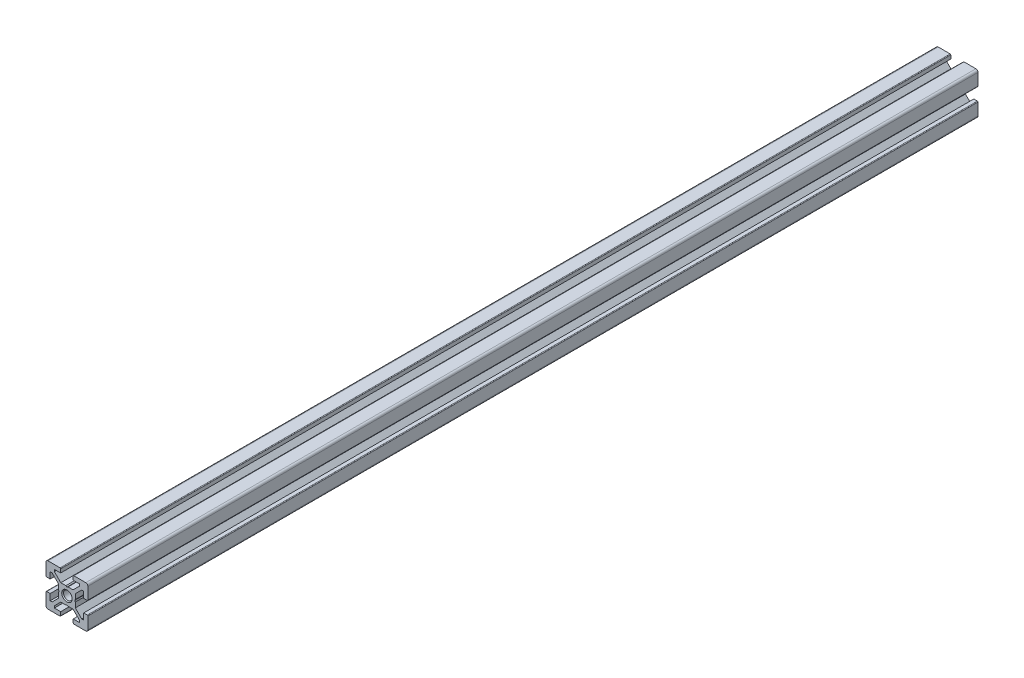
from build123d import *

# Parameters (mm, degrees)
BOSS_EXTRUDE1_DEPTH = 425


with BuildPart() as part:
    # Sketch1 → Boss-Extrude1 (new body)
    with BuildSketch(Plane.XY):
        with BuildLine():
            Line((-10, 9), (-10, 3.29999995))
            ThreePointArc((-10, 3.29999995), (-9.912132049, 3.087867916), (-9.7, 3))
            Line((-9.7, 3), (-8, 3))
            Line((-8, 3), (-8, 6))
            Line((-8, 6), (-7.060677, 6))
            Line((-7.060677, 6), (-4, 2.93932965))
            Line((-4, 2.93932965), (-4, 0.519615242))
            Line((-4, 0.519615242), (-3.699996283, -6.437e-06))
            Line((-3.699996283, -6.437e-06), (-4, -0.519628117))
            Line((-4, -0.519628117), (-4, -2.93933725))
            Line((-4, -2.93933725), (-7.0606695, -6))
            Line((-7.0606695, -6), (-8, -6))
            Line((-8, -6), (-8, -3))
            Line((-8, -3), (-9.7, -3))
            ThreePointArc((-9.7, -3), (-9.912132049, -3.087867916), (-10, -3.29999995))
            Line((-10, -3.29999995), (-10, -9))
            ThreePointArc((-10, -9), (-9.707106781, -9.707106781), (-9, -10))
            Line((-9, -10), (-3.29999995, -10))
            ThreePointArc((-3.29999995, -10), (-3.087867916, -9.912132049), (-3, -9.7))
            Line((-3, -9.7), (-3, -8))
            Line((-3, -8), (-6, -8))
            Line((-6, -8), (-6, -7.0606515))
            Line((-6, -7.0606515), (-2.9393489, -4))
            Line((-2.9393489, -4), (-0.519615242, -4))
            Line((-0.519615242, -4), (6.437e-06, -3.699996283))
            Line((6.437e-06, -3.699996283), (0.519628117, -4))
            Line((0.519628117, -4), (2.9393227, -4))
            Line((2.9393227, -4), (6, -7.060677))
            Line((6, -7.060677), (6, -8))
            Line((6, -8), (3, -8))
            Line((3, -8), (3, -9.7))
            ThreePointArc((3, -9.7), (3.087867916, -9.912132049), (3.29999995, -10))
            Line((3.29999995, -10), (9, -10))
            ThreePointArc((9, -10), (9.707106781, -9.707106781), (10, -9))
            Line((10, -9), (10, -3.29999995))
            ThreePointArc((10, -3.29999995), (9.912132049, -3.087867916), (9.7, -3))
            Line((9.7, -3), (8, -3))
            Line((8, -3), (8, -6))
            Line((8, -6), (7.0606435, -6))
            Line((7.0606435, -6), (4, -2.9393482))
            Line((4, -2.9393482), (4, -0.519615242))
            Line((4, -0.519615242), (3.699996283, 6.437e-06))
            Line((3.699996283, 6.437e-06), (4, 0.519628117))
            Line((4, 0.519628117), (4, 2.9393401))
            Line((4, 2.9393401), (7.060651, 6))
            Line((7.060651, 6), (8, 6))
            Line((8, 6), (8, 3))
            Line((8, 3), (9.7, 3))
            ThreePointArc((9.7, 3), (9.912132049, 3.087867916), (10, 3.29999995))
            Line((10, 3.29999995), (10, 9))
            ThreePointArc((10, 9), (9.707106781, 9.707106781), (9, 10))
            Line((9, 10), (3.29999995, 10))
            ThreePointArc((3.29999995, 10), (3.087867916, 9.912132049), (3, 9.7))
            Line((3, 9.7), (3, 8))
            Line((3, 8), (6, 8))
            Line((6, 8), (6, 7.060669))
            Line((6, 7.060669), (2.9393308, 4))
            Line((2.9393308, 4), (0.519615242, 4))
            Line((0.519615242, 4), (-6.437e-06, 3.699996283))
            Line((-6.437e-06, 3.699996283), (-0.519628117, 4))
            Line((-0.519628117, 4), (-2.93935655, 4))
            Line((-2.93935655, 4), (-6, 7.0606435))
            Line((-6, 7.0606435), (-6, 8))
            Line((-6, 8), (-3, 8))
            Line((-3, 8), (-3, 9.7))
            ThreePointArc((-3, 9.7), (-3.087867966, 9.912132034), (-3.3, 10))
            Line((-3.3, 10), (-9, 10))
            ThreePointArc((-9, 10), (-9.707106781, 9.707106781), (-10, 9))
        make_face()
    extrude(amount=-BOSS_EXTRUDE1_DEPTH)

    # Sketch2 → Cut-Revolve1 (revolve, cut)
    with BuildSketch(Plane(origin=(0, 0, 0), x_dir=(0, 0, -1), z_dir=(1, 0, 0))):
        Polygon((0, 0), (0, 2.5), (0.433, 2.067), (425, 2.067), (425, 0), align=None)
    revolve(axis=Axis((0, 0, -425), (0, 0, 1)), mode=Mode.SUBTRACT)

    # Sketch3 → Cut-Revolve2 (revolve, cut)
    with BuildSketch(Plane(origin=(0, 0, 0), x_dir=(0, 0, -1), z_dir=(1, 0, 0))):
        Polygon((0, 0), (0, 2.067), (424.567, 2.067), (425, 2.5), (425, 0), align=None)
    revolve(axis=Axis((0, 0, -425), (0, 0, 1)), mode=Mode.SUBTRACT)


solid = part.part
